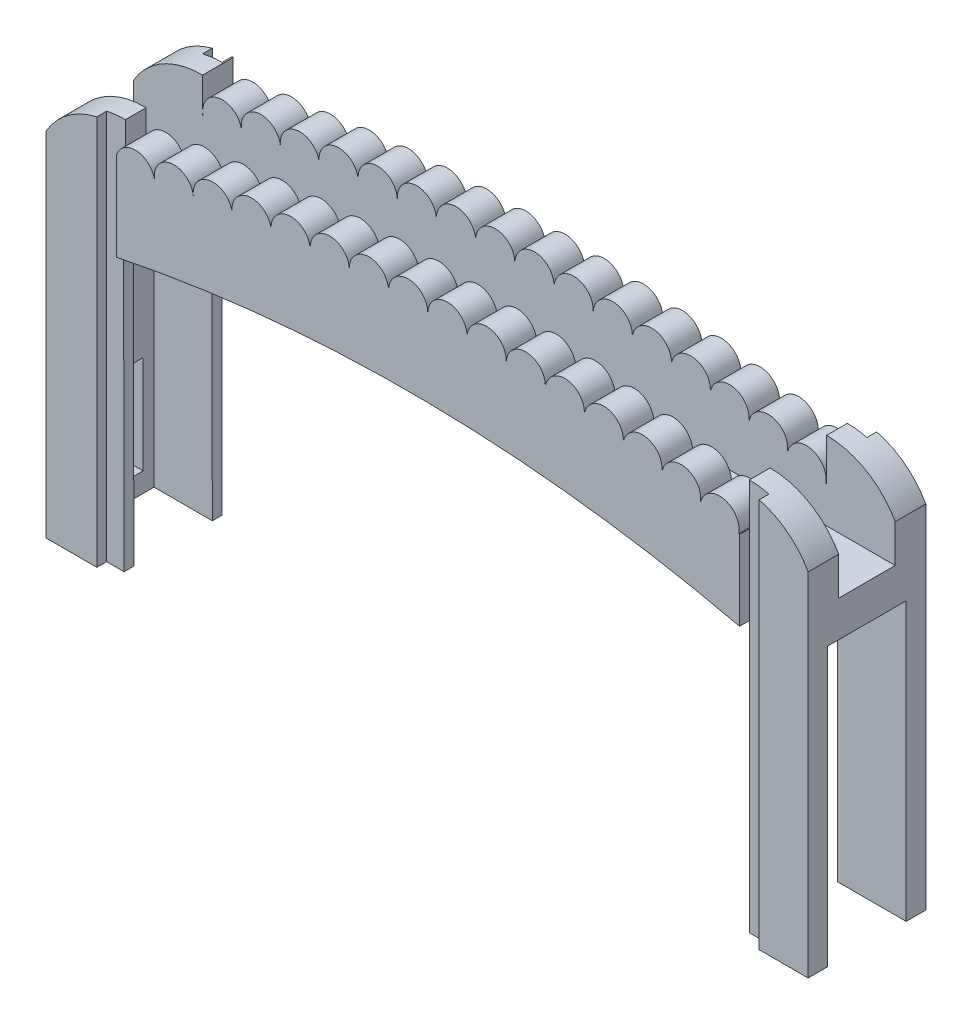
from build123d import *

# Parameters (mm, degrees)
BOSS_EXTRUDE1_DEPTH              = 12.7
SKETCH3_W                        = 4.569606656
SKETCH3_H                        = 12.610946307
CUT_EXTRUDE1_DEPTH               = 32.573497659
CUT_EXTRUDE1_DEPTH_BACK          = 32.704428158
SKETCH4_W                        = 4.569606656
SKETCH4_H                        = 7.9375
CUT_EXTRUDE2_DEPTH               = 66.04
SKETCH5_W                        = 1.5875
SKETCH5_H                        = 39.725965327
CUT_EXTRUDE3_DEPTH               = 32.573497659
CUT_EXTRUDE3_DEPTH_BACK          = 32.704428158
SKETCH6_W                        = 1.5875
SKETCH6_H                        = 40.415060451
CUT_EXTRUDE4_DEPTH               = 0.79375
SKETCH7_W                        = 1.5875
SKETCH7_H                        = 38.718479636
SKETCH7_H_2                      = 39.708151778
CUT_EXTRUDE5_DEPTH               = 0.79375
CUT_EXTRUDE6_REACH               = 9.892
CUT_EXTRUDE6_OFFSET_FROM_SURFACE = 1.5875
SKETCH8_W                        = 6.35
SKETCH8_H                        = 22.490762182
SKETCH9_W                        = 6.35
SKETCH9_H                        = 22.482269966
CUT_EXTRUDE7_DEPTH               = 5.55625
SKETCH10_W                       = 0.79375
SKETCH10_H                       = 36.880517087
CUT_EXTRUDE8_DEPTH               = 12.1125


with BuildPart() as part:
    # Sketch1 → Boss-Extrude1 (new body)
    with BuildSketch(Plane.XY):
        with BuildLine():
            Line((25.223497659, -24.95432425), (31.573497659, -24.95432425))
            Line((31.573497659, -24.95432425), (31.573497659, 0.44567575))
            ThreePointArc((31.573497659, 0.44567575), (29.713625719, 4.935803811), (25.223497659, 6.79567575))
            Line((25.223497659, 6.79567575), (25.223497659, 3.36874218))
            ThreePointArc((25.223497659, 3.36874218), (25.194005143, 3.37526688), (25.164511033, 3.381784371))
            ThreePointArc((25.164511033, 3.381784371), (23.912297459, 5.232947026), (22.049913461, 3.997484421))
            ThreePointArc((22.049913461, 3.997484421), (20.787428344, 5.879791305), (18.929672437, 4.581449722))
            ThreePointArc((18.929672437, 4.581449722), (17.666399498, 6.401938478), (15.813867684, 5.186140916))
            ThreePointArc((15.813867684, 5.186140916), (14.370419451, 6.86745546), (12.652448322, 5.467835298))
            ThreePointArc((12.652448322, 5.467835298), (11.236710182, 7.228730664), (9.494148573, 5.790486593))
            ThreePointArc((9.494148573, 5.790486593), (8.033635968, 7.514426817), (6.328601682, 6.03188675))
            ThreePointArc((6.328601682, 6.03188675), (4.824278861, 7.717733664), (3.157897585, 6.191876393))
            ThreePointArc((3.157897585, 6.191876393), (1.610757722, 7.838516978), (-0.015870376, 6.270349895))
            ThreePointArc((-0.015870376, 6.270349895), (-1.604805836, 7.876697016), (-3.190606835, 6.267255447))
            ThreePointArc((-3.190606835, 6.267255447), (-4.820288856, 7.832248571), (-6.364215787, 6.182595092))
            ThreePointArc((-6.364215787, 6.182595092), (-8.033568431, 7.705200989), (-9.534601973, 6.016424724))
            ThreePointArc((-9.534601973, 6.016424724), (-11.24252311, 7.495638149), (-12.69967226, 5.76885405))
            ThreePointArc((-12.69967226, 5.76885405), (-14.466077033, 7.201365285), (-15.851850507, 5.398061056))
            ThreePointArc((-15.851850507, 5.398061056), (-17.628014087, 6.745603643), (-18.999984081, 4.988240156))
            ThreePointArc((-18.999984081, 4.988240156), (-20.801252814, 6.376658399), (-22.142035626, 4.539656571))
            ThreePointArc((-22.142035626, 4.539656571), (-23.987693231, 5.836740457), (-25.266933007, 3.978670437))
            ThreePointArc((-25.266933007, 3.978670437), (-25.282113604, 3.97569181), (-25.297293828, 3.972711283))
            Line((-25.297293828, 3.972711283), (-25.297293828, 6.794845101))
            ThreePointArc((-25.297293828, 6.794845101), (-29.574532825, 5.2306288), (-31.704428158, 1.205073937))
            Line((-31.704428158, 1.205073937), (-31.704428158, -24.95432425))
            Line((-31.704428158, -24.95432425), (-25.4, -24.95432425))
            Line((-25.4, -24.95432425), (-25.440666935, -2.463598833))
            ThreePointArc((-25.440666935, -2.463598833), (-0.075359426, 0.000928604), (25.223497659, -3.071619312))
            Line((25.223497659, -3.071619312), (25.223497659, -24.95432425))
        make_face()
    extrude(amount=-BOSS_EXTRUDE1_DEPTH)

    # Sketch3 → Cut-Extrude1 (cut, two sides)
    with BuildSketch(Plane(origin=(0, 0, 0), x_dir=(0, 0, -1), z_dir=(1, 0, 0))) as cut_extrude1_sk:
        with Locations((6.35, 6.751148903)):
            Rectangle(SKETCH3_W, SKETCH3_H)
    extrude(amount=CUT_EXTRUDE1_DEPTH, mode=Mode.SUBTRACT)
    extrude(cut_extrude1_sk.sketch, amount=-CUT_EXTRUDE1_DEPTH_BACK, mode=Mode.SUBTRACT)

    # Sketch4 → Cut-Extrude2 (cut)
    with BuildSketch(Plane(origin=(31.573497659, 0, 0), x_dir=(0, 0, -1), z_dir=(1, 0, 0))):
        with Locations((6.35, -19.39807425)):
            Rectangle(SKETCH4_W, SKETCH4_H)
    extrude(amount=-CUT_EXTRUDE2_DEPTH, mode=Mode.SUBTRACT)

    # Sketch5 → Cut-Extrude3 (cut, two sides)
    with BuildSketch(Plane(origin=(0, 0, 0), x_dir=(0, 0, -1), z_dir=(1, 0, 0))) as cut_extrude3_sk:
        with Locations((0.79375, -5.091341587)):
            Rectangle(SKETCH5_W, SKETCH5_H)
        with Locations((11.90625, -5.091341587)):
            Rectangle(SKETCH5_W, SKETCH5_H)
    extrude(amount=CUT_EXTRUDE3_DEPTH, mode=Mode.SUBTRACT)
    extrude(cut_extrude3_sk.sketch, amount=-CUT_EXTRUDE3_DEPTH_BACK, mode=Mode.SUBTRACT)

    # Sketch6 → Cut-Extrude4 (cut)
    with BuildSketch(Plane.XY.offset(-1.5875)):
        with Locations((26.017247659, -4.746794025)):
            Rectangle(SKETCH6_W, SKETCH6_H)
        with Locations((-26.017247659, -4.746794025)):
            Rectangle(SKETCH6_W, SKETCH6_H)
    extrude(amount=-CUT_EXTRUDE4_DEPTH, mode=Mode.SUBTRACT)

    # Sketch7 → Cut-Extrude5 (cut)
    with BuildSketch(Plane(origin=(0, 0, -11.1125), x_dir=(-1, 0, 0), z_dir=(0, 0, -1))):
        with Locations((26.19375, -5.595084432)):
            Rectangle(SKETCH7_W, SKETCH7_H)
        with Locations((-26.017247659, -5.100248361)):
            Rectangle(SKETCH7_W, SKETCH7_H_2)
    extrude(amount=-CUT_EXTRUDE5_DEPTH, mode=Mode.SUBTRACT)

    # Cut-Extrude6: up to this face of the body (flat: up to its plane, moved by the offset)
    cut_extrude6_end = Plane(part.part.faces().sort_by_distance((-31.704428158, -10.78205278, -6.35))[0]).offset(-CUT_EXTRUDE6_OFFSET_FROM_SURFACE)
    # Sketch8 → Cut-Extrude6 (cut, up to the picked face)
    with BuildSketch(Plane(origin=(-25.445038336, -0.046008819, 0), x_dir=(0, 0, -1), z_dir=(0.999998365, 0.001808162, 0)), mode=Mode.PRIVATE) as cut_extrude6_sk1:
        with Locations((6.35, -13.662975058)):
            Rectangle(SKETCH8_W, SKETCH8_H)
    cut_extrude6_tool1 = split(extrude(cut_extrude6_sk1.sketch, amount=-CUT_EXTRUDE6_REACH, mode=Mode.PRIVATE), bisect_by=cut_extrude6_end, keep=Keep.BOTH, mode=Mode.PRIVATE)
    add(cut_extrude6_tool1.solids().sort_by_distance((-25.420333, -13.708962, -6.35))[0], mode=Mode.SUBTRACT)

    # Sketch9 → Cut-Extrude7 (cut)
    with BuildSketch(Plane.ZY.offset(-25.223497659)):
        with Locations((-6.35, -13.713189267)):
            Rectangle(SKETCH9_W, SKETCH9_H)
    extrude(amount=-CUT_EXTRUDE7_DEPTH, mode=Mode.SUBTRACT)

    # Sketch10 → Cut-Extrude8 (cut, through all)
    with BuildSketch(Plane.XY):
        Polygon((-31.704428158, -24.691676413), (-31.704428158, 9.381321615), (-30.910678158, 9.381321615), (-30.910678158, -24.691676413), (-30.910678158, -24.95432425), (-31.704428158, -24.95432425), align=None)
        with Locations((31.176622659, -6.514065707)):
            Rectangle(SKETCH10_W, SKETCH10_H)
    extrude(amount=-CUT_EXTRUDE8_DEPTH, mode=Mode.SUBTRACT)


solid = part.part
